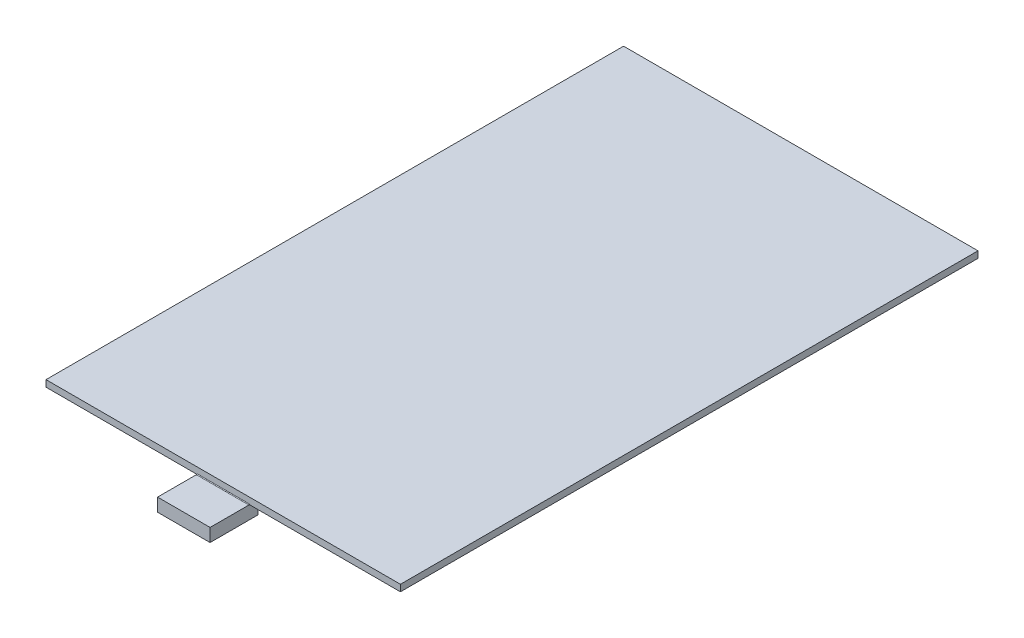
from build123d import *

# Parameters (mm, degrees)
SKETCH1_W           = 54
SKETCH1_H           = 88
BOSS_EXTRUDE1_DEPTH = 1
BOSS_EXTRUDE2_DEPTH = 2
FILLET4_R           = 0.1
FILLET5_R           = 0.1


with BuildPart() as part:
    # Sketch1 → Boss-Extrude1 (new body)
    with BuildSketch(Plane(origin=(0, 0, 0), x_dir=(1, 0, 0), z_dir=(0, 1, 0))):
        Rectangle(SKETCH1_W, SKETCH1_H)
    extrude(amount=BOSS_EXTRUDE1_DEPTH)

    # Sketch2 → Boss-Extrude2 (add)
    with BuildSketch(Plane.XZ):
        Polygon((-4, 42.7), (4, 42.7), (4, 44), (4, 50), (-4, 50), (-4, 44), align=None)
    extrude(amount=BOSS_EXTRUDE2_DEPTH)

    # Fillet4
    fillet4_edges = [part.edges().sort_by_distance(p)[0] for p in [
        (0, 0, 44),
    ]]
    fillet(fillet4_edges, radius=FILLET4_R)

    # Fillet5
    fillet5_edges = [part.edges().sort_by_distance(p)[0] for p in [
        (-4, 0, 43.35),
        (0, 0, 42.7),
        (4, 0, 43.35),
    ]]
    fillet(fillet5_edges, radius=FILLET5_R)


solid = part.part
